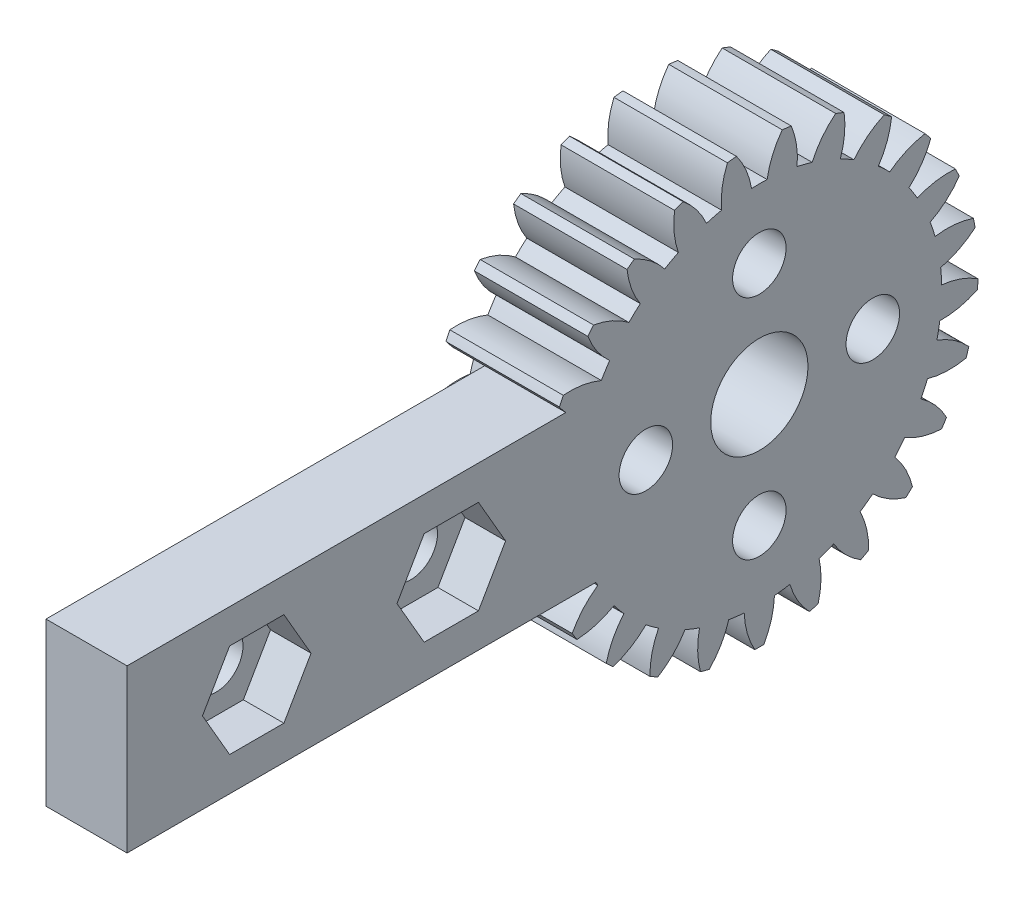
from build123d import *

# Parameters (mm, degrees)
BASPROSKE_W         = 7
BASPROSKE_H         = 13.5
TOOTHCUT_DEPTH      = 21.334699408
TEETHCUTS_COUNT     = 25
TEETHCUTS_ANGLE     = 345.6
BORSKE_R            = 0.4
BORE_DEPTH          = 50.0000508
SKETCH_1_R          = 3
SKETCH_1_R_2        = 1.65
CUT_EXTRUDE_1_DEPTH = 10
SKETCH_2_W          = 30
SKETCH_2_H          = 10
SKETCH_2_R          = 1.65
EXTRUDE_2_DEPTH     = 5
CUT_EXTRUDE_2_DEPTH = 2.5


with BuildPart() as part:
    # BasProSke → Base-Revolve (revolve)
    with BuildSketch(Plane(origin=(0, 0, 0), x_dir=(1, 0, 0), z_dir=(0, 1, 0)), mode=Mode.PRIVATE) as base_revolve_sk:
        with Locations((3.5, 6.75)):
            Rectangle(BASPROSKE_W, BASPROSKE_H)
    revolve(base_revolve_sk.sketch.rotate(Axis((-10, 0, 0), (1, 0, 0)), 180), axis=Axis((-10, 0, 0), (1, 0, 0)))

    # TooCutSke → ToothCut (cut, through all)
    with BuildSketch(Plane(origin=(0, 0, 0), x_dir=(0, 0, -1), z_dir=(1, 0, 0))):
        with BuildLine():
            ThreePointArc((0.480087995, 11.238750665), (0, 11.249), (-0.480087995, 11.238750665))
            ThreePointArc((-0.480087995, 11.238750665), (-0.821124963, 12.40220054), (-1.432168974, 13.449361962))
            ThreePointArc((-1.432168974, 13.449361962), (0, 13.5254), (1.432168974, 13.449361962))
            ThreePointArc((1.432168974, 13.449361962), (0.821124963, 12.40220054), (0.480087995, 11.238750665))
        make_face()
    toothcut = extrude(amount=TOOTHCUT_DEPTH, mode=Mode.SUBTRACT)

    # TeethCuts: ToothCut ×25 about axis
    teethcuts_axis = Axis((-10, 0, 0), (1, 0, 0))
    for i in range(1, TEETHCUTS_COUNT):
        add(toothcut.rotate(teethcuts_axis, i * TEETHCUTS_ANGLE / (TEETHCUTS_COUNT - 1)), mode=Mode.SUBTRACT)

    # BorSke → Bore (cut, symmetric)
    with BuildSketch(Plane(origin=(0, 0, 0), x_dir=(0, 0, -1), z_dir=(1, 0, 0))):
        with Locations(Location((0, 0, 0), (0, 0, 180))):
            Circle(BORSKE_R)
    extrude(amount=BORE_DEPTH, both=True, mode=Mode.SUBTRACT)

    # 草图1 → 切除-拉伸1 (cut)
    with BuildSketch(Plane(origin=(7, 0, 0), x_dir=(0, 0, -1), z_dir=(1, 0, 0))):
        Circle(SKETCH_1_R)
        with Locations((0, 7)):
            Circle(SKETCH_1_R_2)
        with Locations((7, 0)):
            Circle(SKETCH_1_R_2)
        with Locations((-7, 0)):
            Circle(SKETCH_1_R_2)
        with Locations((0, -7)):
            Circle(SKETCH_1_R_2)
    extrude(amount=-CUT_EXTRUDE_1_DEPTH, mode=Mode.SUBTRACT)

    # 草图2 → 凸台-拉伸2 (add)
    with BuildSketch(Plane(origin=(7, 0, 0), x_dir=(0, 0, -1), z_dir=(1, 0, 0))):
        with Locations((-24, 0)):
            Rectangle(SKETCH_2_W, SKETCH_2_H)
        with Locations((-31, 0)):
            Circle(SKETCH_2_R, mode=Mode.SUBTRACT)
        with Locations((-19, 0)):
            Circle(SKETCH_2_R, mode=Mode.SUBTRACT)
    extrude(amount=-EXTRUDE_2_DEPTH)

    # 草图3 → 切除-拉伸2 (cut)
    with BuildSketch(Plane(origin=(7, 0, 0), x_dir=(0, 0, -1), z_dir=(1, 0, 0))):
        Polygon((-15.651368439, 0), (-17.325684219, 2.9), (-20.674315781, 2.9), (-22.348631561, 0), (-20.674315781, -2.9), (-17.325684219, -2.9), align=None)
        Polygon((-27.651368439, 0), (-29.325684219, 2.9), (-32.674315781, 2.9), (-34.348631561, 0), (-32.674315781, -2.9), (-29.325684219, -2.9), align=None)
    extrude(amount=-CUT_EXTRUDE_2_DEPTH, mode=Mode.SUBTRACT)


solid = part.part
